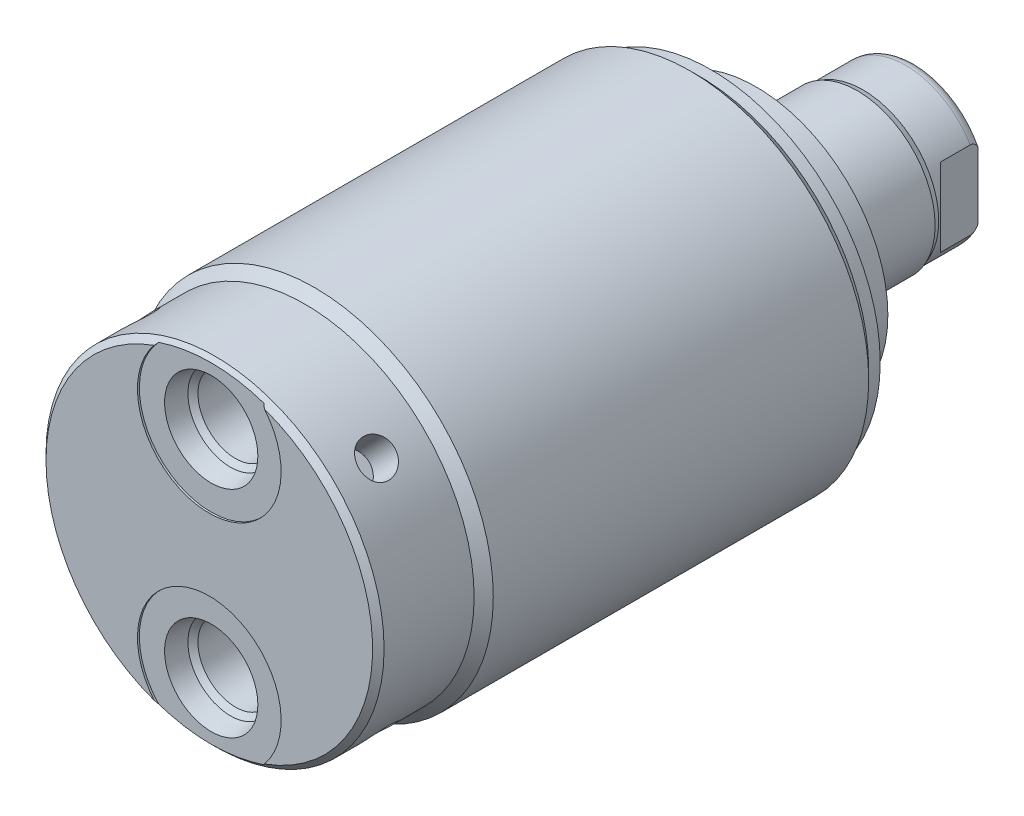
from build123d import *

# Parameters (mm, degrees)
SKETCH1_R          = 23.6855
EXTRUDE1_DEPTH     = 66.548
CHAMFER1_SIZE      = 0.762
SKETCH6_R          = 17.4625
EXTRUDE2_DEPTH     = 5.969
SKETCH7_W          = 20.828
SKETCH7_H          = 10.31875
CUT_EXTRUDE4_DEPTH = 19.84248
HOLE1_D            = 4.7498
HOLE1_DEPTH        = 4.7498
CIRPATTERN1_COUNT  = 4
LPATTERN1_COUNT    = 2
LPATTERN1_PITCH    = 28.5496


with BuildPart() as part:
    # Sketch1 → Extrude1 (new body)
    with BuildSketch(Plane.XY):
        Circle(SKETCH1_R)
    extrude(amount=EXTRUDE1_DEPTH)

    # Sketch2 → Cut-Revolve1 (revolve, cut)
    with BuildSketch(Plane(origin=(0, 0, 0), x_dir=(1, 0, 0), z_dir=(0, 1, 0)), mode=Mode.PRIVATE) as cut_revolve1_sk:
        Polygon((23.6855, -66.548), (23.6855, -52.578), (22.4155, -53.848), (22.4155, -66.548), align=None)
    revolve(cut_revolve1_sk.sketch.rotate(Axis((0, 0, 0), (0, 0, 1)), 180), axis=Axis((0, 0, 0), (0, 0, 1)), mode=Mode.SUBTRACT)  # turned: the seam where the file's is

    # Sketch3 → Cut-Revolve2 (revolve, cut)
    with BuildSketch(Plane(origin=(0, 0, 0), x_dir=(1, 0, 0), z_dir=(0, 1, 0)), mode=Mode.PRIVATE) as cut_revolve2_sk:
        Polygon((22.4155, 0), (22.4155, -1.524), (23.6855, -2.794), (23.6855, 0), align=None)
    revolve(cut_revolve2_sk.sketch.rotate(Axis((0, 0, 0), (0, 0, -1)), 180), axis=Axis((0, 0, 0), (0, 0, -1)), mode=Mode.SUBTRACT)  # turned: the seam where the file's is

    # Chamfer1
    chamfer1_edges = [part.edges().sort_by_distance(p)[0] for p in [
        (22.4155, 0, 66.548),
    ]]
    chamfer(chamfer1_edges, length=CHAMFER1_SIZE)

    # S2D0002 → Cut-Revolve3 (revolve, cut)
    with BuildSketch(Plane(origin=(0, 0, 0), x_dir=(0, -1, 0), z_dir=(1, 0, 0)), mode=Mode.PRIVATE) as cut_revolve3_sk:
        Polygon((20.4597, -66.294), (23.7998, -66.294), (23.7998, -66.548), (14.2748, -66.548), (14.2748, -52.324), (19.2532, -52.324), (19.2532, -63.077393135), (19.917106865, -63.7413), align=None)
    cut_revolve3 = revolve(cut_revolve3_sk.sketch.rotate(Axis((0, -14.2748, 14.6685), (0, 0, -1)), 270), axis=Axis((0, -14.2748, 14.6685), (0, 0, -1)), mode=Mode.SUBTRACT)  # turned: the seam where the file's is

    # Sketch6 → Extrude2 (add)
    with BuildSketch(Plane(origin=(0, 0, 0), x_dir=(-1, 0, 0), z_dir=(0, 0, -1))):
        with Locations(Location((0, 0, 0), (0, 0, 180))):  # turned: the seam where the file's is
            Circle(SKETCH6_R)
    extrude(amount=EXTRUDE2_DEPTH)

    # Sketch7 → Revolve1 (revolve)
    with BuildSketch(Plane(origin=(0, 0, 0), x_dir=(0, 0, -1), z_dir=(1, 0, 0)), mode=Mode.PRIVATE) as revolve1_sk:
        with Locations((16.383, -5.159375)):
            Rectangle(SKETCH7_W, SKETCH7_H)
    revolve(revolve1_sk.sketch.rotate(Axis((0, 0, 0), (0, 0, -1)), 90), axis=Axis((0, 0, 0), (0, 0, -1)))  # turned: the seam where the file's is

    # S2D0001 → Cut-Revolve5 (revolve, cut)
    with BuildSketch(Plane(origin=(0, 0, 0), x_dir=(1, 0, 0), z_dir=(0, 1, 0))):
        Polygon((3.2639, 24.861260017), (3.2639, 11.9888), (0, 11.9888), (0, 26.797), (4.3815, 26.797), align=None)
    revolve(axis=Axis((0, 0, 31.308359971), (0, 0, -1)), mode=Mode.SUBTRACT)

    # Sketch9 → Cut-Revolve6 (revolve, cut)
    with BuildSketch(Plane(origin=(0, 0, 0), x_dir=(0, -1, 0), z_dir=(1, 0, 0)), mode=Mode.PRIVATE) as cut_revolve6_sk:
        with BuildLine():
            Line((-10.31875, 19.3802), (-10.033, 20.1422))
            Line((-10.033, 20.1422), (-10.033, 25.781))
            ThreePointArc((-10.033, 25.781), (-9.932678675, 26.324796865), (-9.644922533, 26.797))
            Line((-9.644922533, 26.797), (-10.31875, 26.797))
            Line((-10.31875, 26.797), (-10.31875, 19.3802))
        make_face()
    revolve(cut_revolve6_sk.sketch.rotate(Axis((0, 0, -12.65936), (0, 0, -1)), 90), axis=Axis((0, 0, -12.65936), (0, 0, -1)), mode=Mode.SUBTRACT)  # turned: the seam where the file's is

    # Sketch13 → Cut-Extrude4 (cut, symmetric)
    with BuildSketch(Plane(origin=(0, 0, 0), x_dir=(1, 0, 0), z_dir=(0, 1, 0))):
        Polygon((8.5852, 26.797), (8.5852, 21.844), (10.033, 20.3962), (10.033, 26.797), align=None)
        Polygon((-8.5852, 26.797), (-8.5852, 21.844), (-10.033, 20.3962), (-10.033, 26.797), align=None)
    extrude(amount=CUT_EXTRUDE4_DEPTH, both=True, mode=Mode.SUBTRACT)

    # Hole1
    with Locations(Plane(origin=(-15.850152054, 15.850152054, 60.198), x_dir=(0.707106781, 0.707106781, 0), z_dir=(-0.707106781, 0.707106781, 0))):
        with Locations((0, 0)):
            hole1 = Hole(HOLE1_D / 2, depth=HOLE1_DEPTH)

    # CirPattern1: Hole1 ×4 about axis
    cirpattern1_axis = Axis((0, 0, 0), (0, 0, 1))
    for i in range(1, CIRPATTERN1_COUNT):
        add(hole1.rotate(cirpattern1_axis, i * 360 / CIRPATTERN1_COUNT), mode=Mode.SUBTRACT)

    # LPattern1: Cut-Revolve3 ×2
    with Locations(*[(0, i * LPATTERN1_PITCH, 0) for i in range(1, LPATTERN1_COUNT)]):
        add(cut_revolve3, mode=Mode.SUBTRACT)


solid = part.part
